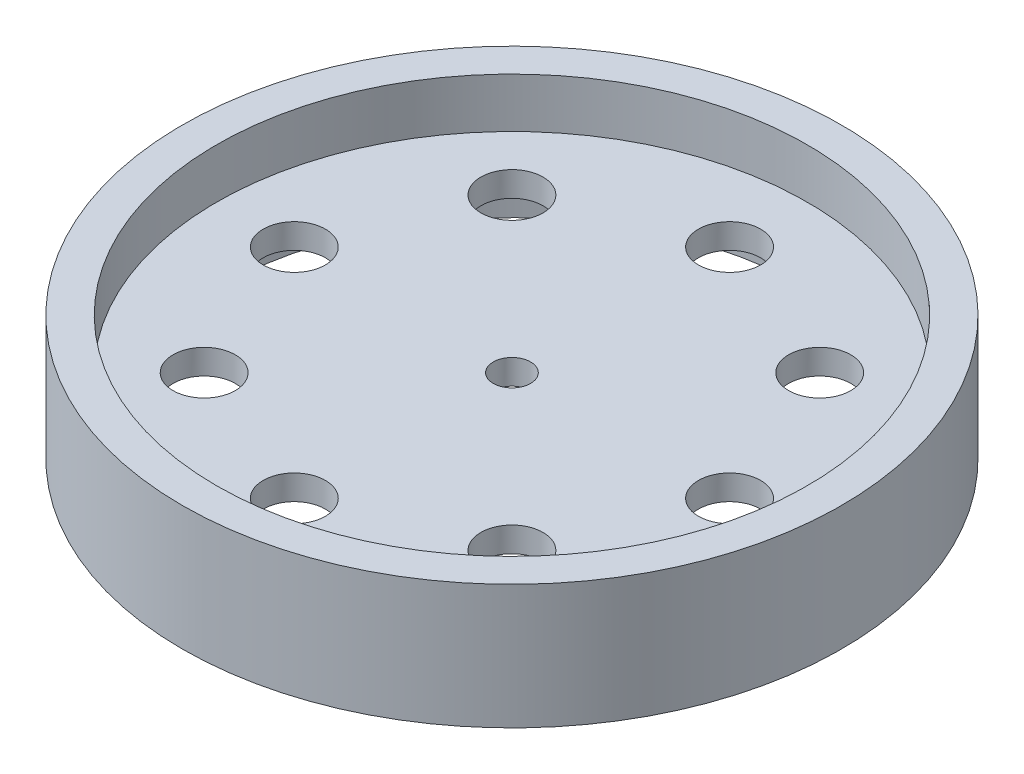
from build123d import *

# Parameters (mm, degrees)
SKETCH1_R           = 53
SKETCH1_R_2         = 43
BOSS_EXTRUDE1_DEPTH = 20
SKETCH2_R           = 43
BOSS_EXTRUDE2_DEPTH = 20
SKETCH3_R           = 47.5
CUT_EXTRUDE1_DEPTH  = 8
SKETCH4_R           = 47.5
CUT_EXTRUDE2_DEPTH  = 8
SKETCH5_R           = 3
SKETCH5_R_2         = 5
CUT_EXTRUDE3_DEPTH  = 13


with BuildPart() as part:
    # Sketch1 → Boss-Extrude1 (new body)
    with BuildSketch(Plane(origin=(0, 0, 0), x_dir=(1, 0, 0), z_dir=(0, 1, 0))):
        Circle(SKETCH1_R)
        Circle(SKETCH1_R_2, mode=Mode.SUBTRACT)
    extrude(amount=BOSS_EXTRUDE1_DEPTH)

    # Sketch2 → Boss-Extrude2 (add)
    with BuildSketch(Plane(origin=(0, 20, 0), x_dir=(1, 0, 0), z_dir=(0, 1, 0))):
        Circle(SKETCH2_R)
    extrude(amount=-BOSS_EXTRUDE2_DEPTH)

    # Sketch3 → Cut-Extrude1 (cut)
    with BuildSketch(Plane(origin=(0, 20, 0), x_dir=(1, 0, 0), z_dir=(0, 1, 0))):
        Circle(SKETCH3_R)
    extrude(amount=-CUT_EXTRUDE1_DEPTH, mode=Mode.SUBTRACT)

    # Sketch4 → Cut-Extrude2 (cut)
    with BuildSketch(Plane.XZ):
        Circle(SKETCH4_R)
    extrude(amount=-CUT_EXTRUDE2_DEPTH, mode=Mode.SUBTRACT)

    # Sketch5 → Cut-Extrude3 (cut, through all)
    with BuildSketch(Plane(origin=(0, 12, 0), x_dir=(1, 0, 0), z_dir=(0, 1, 0))):
        Circle(SKETCH5_R)
        with Locations((0, 35)):
            Circle(SKETCH5_R_2)
        with Locations((24.748737342, 24.748737342)):
            Circle(SKETCH5_R_2)
        with Locations((35, 0)):
            Circle(SKETCH5_R_2)
        with Locations((24.748737342, -24.748737342)):
            Circle(SKETCH5_R_2)
        with Locations((0, -35)):
            Circle(SKETCH5_R_2)
        with Locations((-24.748737342, -24.748737342)):
            Circle(SKETCH5_R_2)
        with Locations((-35, 0)):
            Circle(SKETCH5_R_2)
        with Locations((-24.748737342, 24.748737342)):
            Circle(SKETCH5_R_2)
    extrude(amount=-CUT_EXTRUDE3_DEPTH, mode=Mode.SUBTRACT)


solid = part.part
